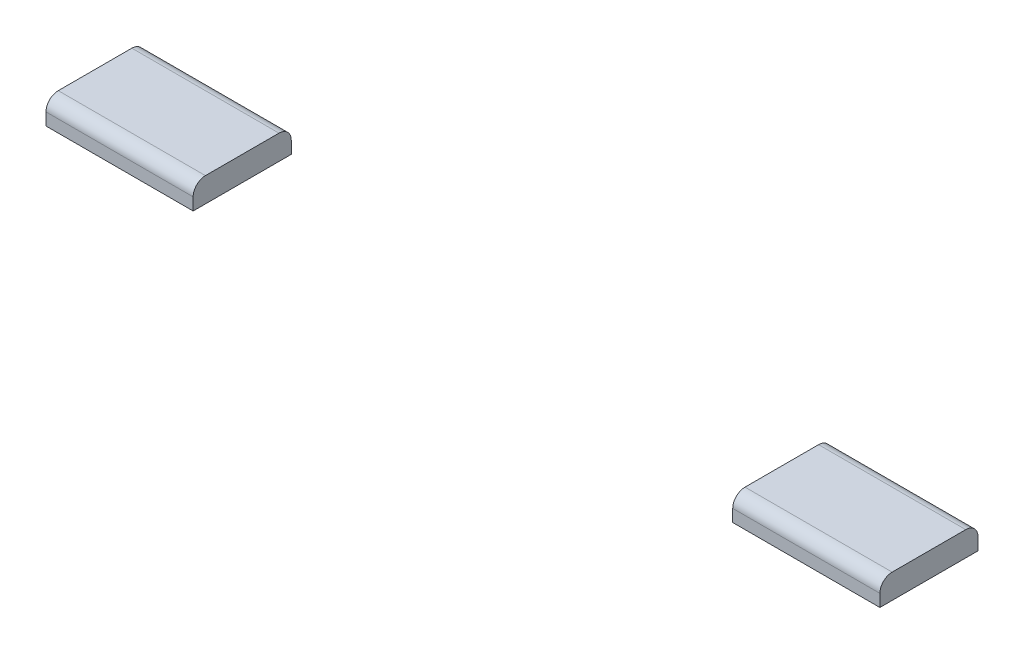
from build123d import *

# Parameters (mm, degrees)
SKETCH1_W           = 215.9
SKETCH1_H           = 25.4
BOSS_EXTRUDE1_DEPTH = 6.35
FILLET1_R           = 3.175
SKETCH2_W           = 139.7
SKETCH2_H           = 25.4
CUT_EXTRUDE1_DEPTH  = 7.35


with BuildPart() as part:
    # Sketch1 → Boss-Extrude1 (new body)
    with BuildSketch(Plane(origin=(0, 0, 0), x_dir=(1, 0, 0), z_dir=(0, 1, 0))):
        with Locations((107.95, 12.7)):
            Rectangle(SKETCH1_W, SKETCH1_H)
    extrude(amount=BOSS_EXTRUDE1_DEPTH)

    # Fillet1
    fillet1_edges = [part.edges().sort_by_distance(p)[0] for p in [
        (107.95, 6.35, -25.4),
        (107.95, 6.35, 0),
    ]]
    fillet(fillet1_edges, radius=FILLET1_R)

    # Sketch2 → Cut-Extrude1 (cut, through all)
    with BuildSketch(Plane.XZ):
        with Locations((107.95, -12.7)):
            Rectangle(SKETCH2_W, SKETCH2_H)
    extrude(amount=-CUT_EXTRUDE1_DEPTH, mode=Mode.SUBTRACT)


solid = part.part
